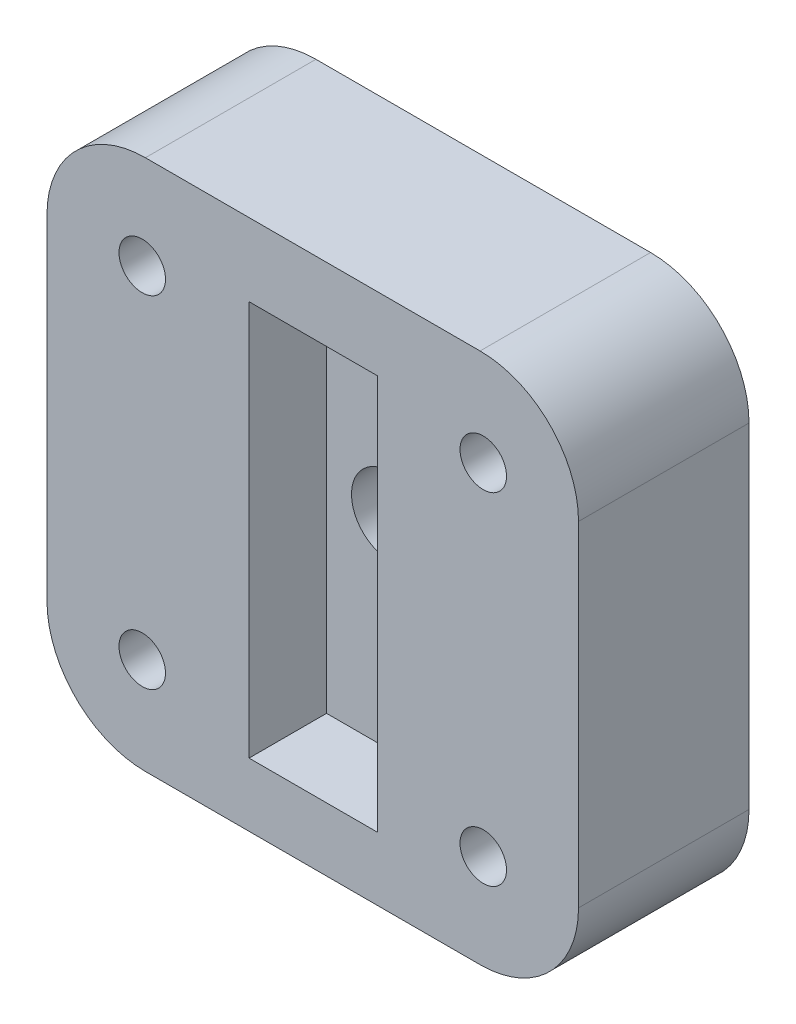
from build123d import *

# Parameters (mm, degrees)
SKETCH1_W           = 34.29
SKETCH1_H           = 34.29
SKETCH1_R           = 1.5
BOSS_EXTRUDE1_DEPTH = 11
SKETCH2_W           = 8.3
SKETCH2_H           = 25.5
CUT_EXTRUDE1_DEPTH  = 5
SKETCH3_R           = 2.5
CUT_EXTRUDE2_DEPTH  = 5
SKETCH5_R           = 4.15
CUT_EXTRUDE4_DEPTH  = 3
FILLET2_R           = 6.35


with BuildPart() as part:
    # Sketch1 → Boss-Extrude1 (new body)
    with BuildSketch(Plane.XY):
        Rectangle(SKETCH1_W, SKETCH1_H)
        with Locations((-11, 11)):
            Circle(SKETCH1_R, mode=Mode.SUBTRACT)
        with Locations((11, 11)):
            Circle(SKETCH1_R, mode=Mode.SUBTRACT)
        with Locations((-11, -11)):
            Circle(SKETCH1_R, mode=Mode.SUBTRACT)
        with Locations((11, -11)):
            Circle(SKETCH1_R, mode=Mode.SUBTRACT)
    extrude(amount=BOSS_EXTRUDE1_DEPTH)

    # Sketch2 → Cut-Extrude1 (cut)
    with BuildSketch(Plane.XY.offset(11)):
        with Locations((0.041, -0.304)):
            Rectangle(SKETCH2_W, SKETCH2_H)
    extrude(amount=-CUT_EXTRUDE1_DEPTH, mode=Mode.SUBTRACT)

    # Sketch3 → Cut-Extrude2 (cut)
    with BuildSketch(Plane.XY.offset(6)):
        Circle(SKETCH3_R)
    extrude(amount=-CUT_EXTRUDE2_DEPTH, mode=Mode.SUBTRACT)

    # Sketch5 → Cut-Extrude4 (cut)
    with BuildSketch(Plane(origin=(0, 0, 0), x_dir=(-1, 0, 0), z_dir=(0, 0, -1))):
        Circle(SKETCH5_R)
    extrude(amount=-CUT_EXTRUDE4_DEPTH, mode=Mode.SUBTRACT)

    # Fillet2
    fillet2_edges = [part.edges().sort_by_distance(p)[0] for p in [
        (17.145, -17.145, 5.5),
        (-17.145, -17.145, 5.5),
        (-17.145, 17.145, 5.5),
        (17.145, 17.145, 5.5),
    ]]
    fillet(fillet2_edges, radius=FILLET2_R)


solid = part.part
